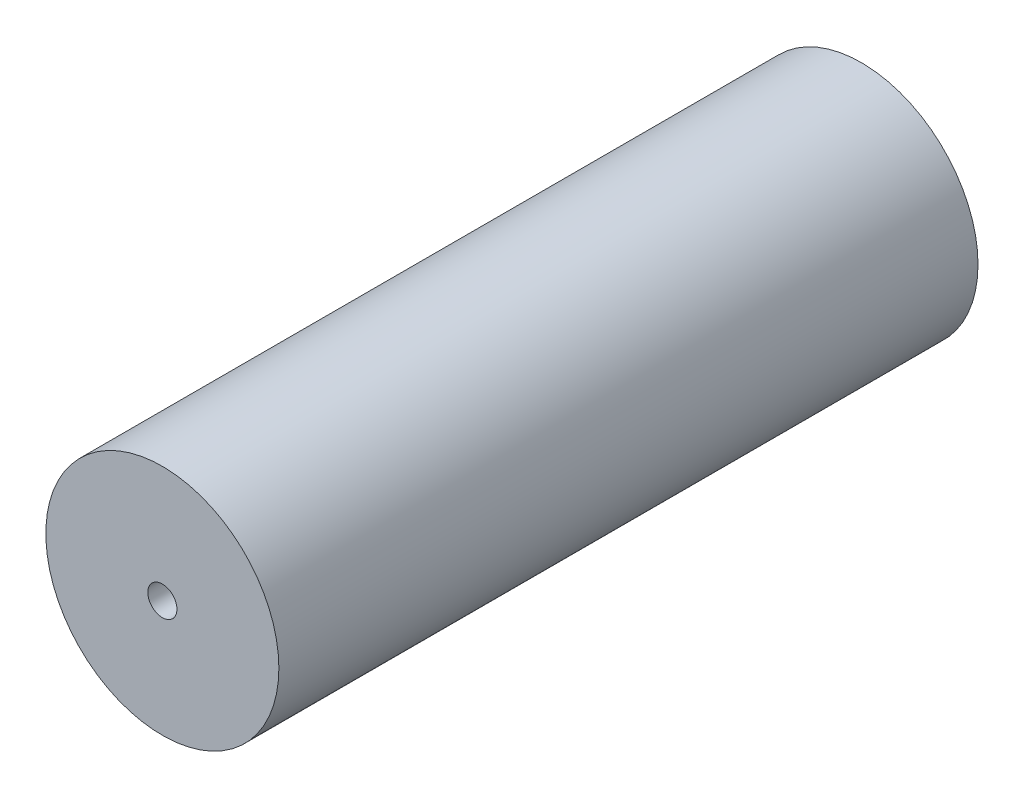
from build123d import *

# Parameters (mm, degrees)
SKETCH3_R           = 25.4
BOSS_EXTRUDE1_DEPTH = 152.4
SKETCH4_R           = 3.175
CUT_EXTRUDE1_DEPTH  = 25.4


with BuildPart() as part:
    # Sketch3 → Boss-Extrude1 (new body)
    with BuildSketch(Plane.XY):
        Circle(SKETCH3_R)
    extrude(amount=BOSS_EXTRUDE1_DEPTH)

    # Sketch4 → Cut-Extrude1 (cut)
    with BuildSketch(Plane.XY.offset(152.4)):
        Circle(SKETCH4_R)
    extrude(amount=-CUT_EXTRUDE1_DEPTH, mode=Mode.SUBTRACT)


solid = part.part
